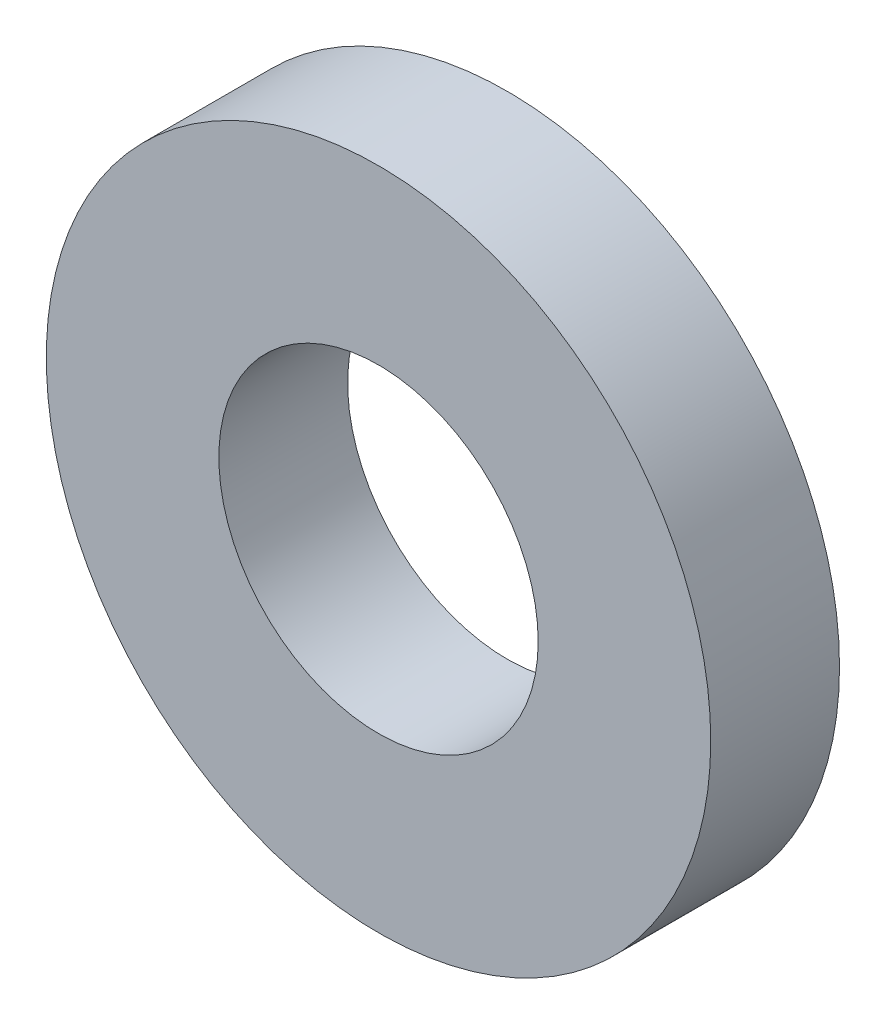
from build123d import *

# Parameters (mm, degrees)
ESQUISSE1_R        = 12.9
ESQUISSE1_R_2      = 6.2
BOSS_EXTRU_1_DEPTH = 5


with BuildPart() as part:
    # Esquisse1 → Boss.-Extru.1 (new body)
    with BuildSketch(Plane.XY):
        Circle(ESQUISSE1_R)
        Circle(ESQUISSE1_R_2, mode=Mode.SUBTRACT)
    extrude(amount=BOSS_EXTRU_1_DEPTH)


solid = part.part
